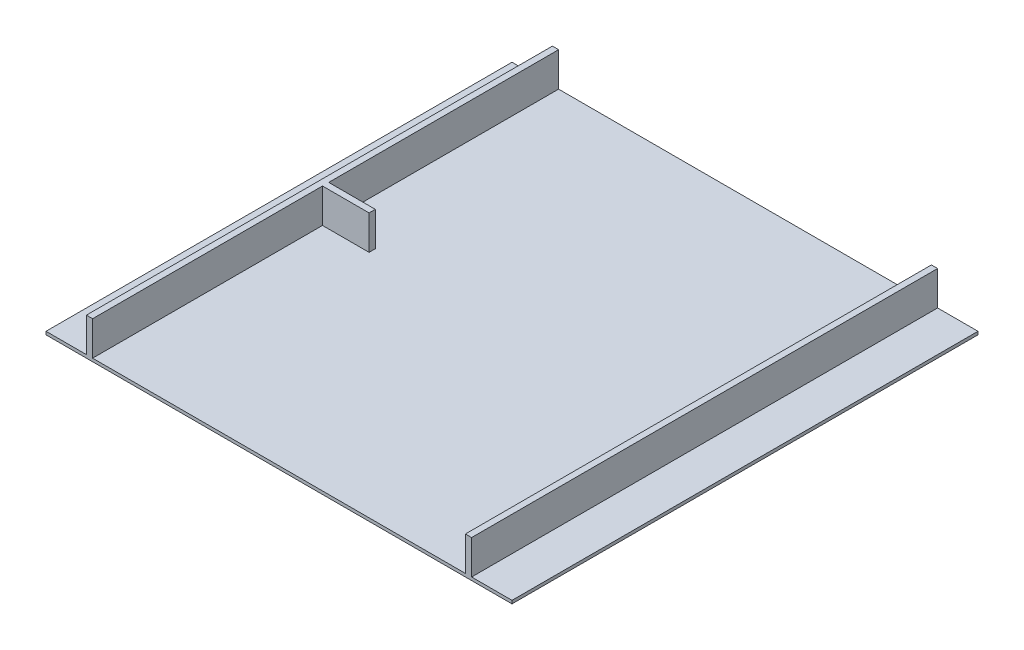
from build123d import *

# Parameters (mm, degrees)
SKETCH2_W           = 1500
SKETCH2_H           = 1500
BOSS_EXTRUDE1_DEPTH = 10
SKETCH3_W           = 150
SKETCH3_H           = 20
SKETCH3_W_2         = 20
SKETCH3_H_2         = 1500
BOSS_EXTRUDE2_DEPTH = 110


with BuildPart() as part:
    # Sketch2 → Boss-Extrude1 (new body)
    with BuildSketch(Plane(origin=(0, 0, 0), x_dir=(1, 0, 0), z_dir=(0, 1, 0))):
        Rectangle(SKETCH2_W, SKETCH2_H)
    extrude(amount=BOSS_EXTRUDE1_DEPTH)

    # Sketch3 → Boss-Extrude2 (add)
    with BuildSketch(Plane(origin=(0, 10, 0), x_dir=(1, 0, 0), z_dir=(0, 1, 0))):
        Polygon((-600, 750), (-620, 750), (-620, -750), (-600, -750), (-600, -10), (-600, 10), align=None)
        with Locations((-525, 0)):
            Rectangle(SKETCH3_W, SKETCH3_H)
        with Locations((610, 0)):
            Rectangle(SKETCH3_W_2, SKETCH3_H_2)
    extrude(amount=BOSS_EXTRUDE2_DEPTH)


solid = part.part
